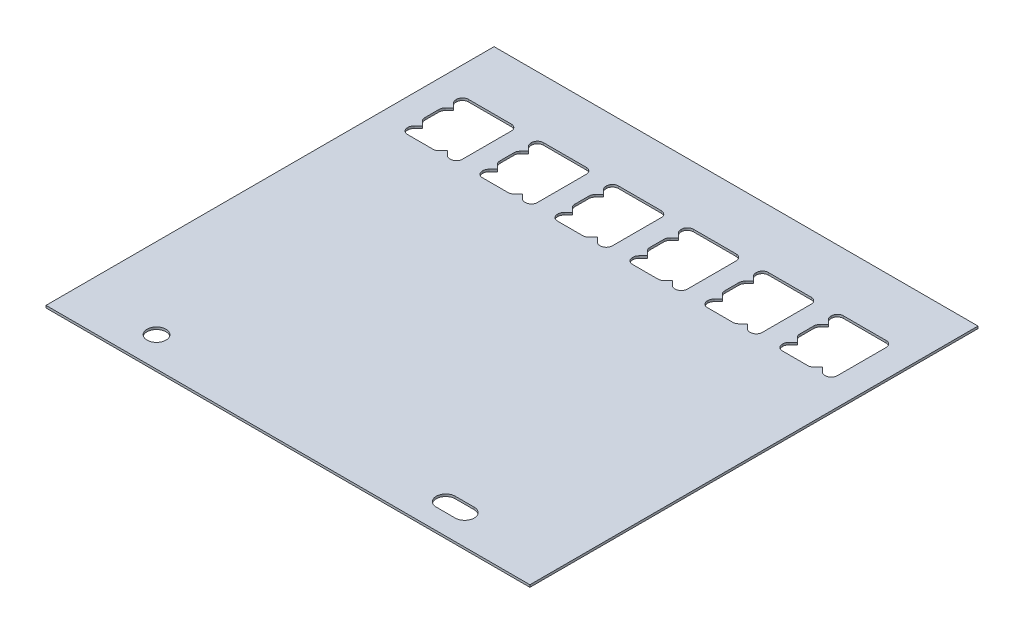
from build123d import *

# Parameters (mm, degrees)
SKETCH1_W           = 81
SKETCH1_H           = 75
BOSS_EXTRUDE1_DEPTH = 0.381
SKETCH2_R           = 1.585
CUT_EXTRUDE1_DEPTH  = 1.381


with BuildPart() as part:
    # Sketch1 → Boss-Extrude1 (new body)
    with BuildSketch(Plane(origin=(0, 0, 0), x_dir=(1, 0, 0), z_dir=(0, 1, 0))):
        with Locations((40.5, 37.5)):
            Rectangle(SKETCH1_W, SKETCH1_H)
    extrude(amount=-BOSS_EXTRUDE1_DEPTH)

    # Sketch2 → Cut-Extrude1 (cut, through all)
    with BuildSketch(Plane(origin=(0, 0, 0), x_dir=(1, 0, 0), z_dir=(0, 1, 0))):
        with Locations(Location((13.5, 5, 0), (0, 0, 270))):  # turned: the seam where the file's is
            Circle(SKETCH2_R)
        with BuildLine():
            Line((61.915, 6.585), (65.085, 6.585))
            ThreePointArc((65.085, 6.585), (66.67, 5), (65.085, 3.415))
            Line((65.085, 3.415), (61.915, 3.415))
            ThreePointArc((61.915, 3.415), (60.33, 5), (61.915, 6.585))
        make_face()
        with BuildLine():
            Line((5.49, 55.02), (9.755786438, 55.02))
            ThreePointArc((9.755786438, 55.02), (10.13846987, 55.096120467), (10.462893219, 55.312893219))
            Line((10.462893219, 55.312893219), (11.17, 56.02))
            Line((11.17, 56.02), (11.877106781, 55.312893219))
            ThreePointArc((11.877106781, 55.312893219), (12.20153013, 55.096120467), (12.584213562, 55.02))
            Line((12.584213562, 55.02), (12.67, 55.02))
            ThreePointArc((12.67, 55.02), (13.377106781, 55.312893219), (13.67, 56.02))
            Line((13.67, 56.02), (13.67, 64.22))
            ThreePointArc((13.67, 64.22), (13.377106781, 64.927106781), (12.67, 65.22))
            Line((12.67, 65.22), (5.49, 65.22))
            ThreePointArc((5.49, 65.22), (4.782893219, 64.927106781), (4.49, 64.22))
            Line((4.49, 64.22), (4.49, 64.134213564))
            ThreePointArc((4.49, 64.134213564), (4.566120467, 63.751530131), (4.782893219, 63.427106782))
            Line((4.782893219, 63.427106782), (5.490000001, 62.72))
            Line((5.490000001, 62.72), (4.782893219, 62.012893218))
            ThreePointArc((4.782893219, 62.012893218), (4.566120467, 61.688469869), (4.49, 61.305786436))
            Line((4.49, 61.305786436), (4.49, 58.934213562))
            ThreePointArc((4.49, 58.934213562), (4.566120467, 58.55153013), (4.782893219, 58.227106781))
            Line((4.782893219, 58.227106781), (5.49, 57.52))
            Line((5.49, 57.52), (4.782893219, 56.812893219))
            ThreePointArc((4.782893219, 56.812893219), (4.566120467, 56.48846987), (4.49, 56.105786438))
            Line((4.49, 56.105786438), (4.49, 56.02))
            ThreePointArc((4.49, 56.02), (4.782893219, 55.312893219), (5.49, 55.02))
        make_face()
        with BuildLine():
            Line((18.04, 55.02), (22.305786438, 55.02))
            ThreePointArc((22.305786438, 55.02), (22.68846987, 55.096120467), (23.012893219, 55.312893219))
            Line((23.012893219, 55.312893219), (23.72, 56.02))
            Line((23.72, 56.02), (24.427106781, 55.312893219))
            ThreePointArc((24.427106781, 55.312893219), (24.75153013, 55.096120467), (25.134213562, 55.02))
            Line((25.134213562, 55.02), (25.22, 55.02))
            ThreePointArc((25.22, 55.02), (25.927106781, 55.312893219), (26.22, 56.02))
            Line((26.22, 56.02), (26.22, 64.22))
            ThreePointArc((26.22, 64.22), (25.927106781, 64.927106781), (25.22, 65.22))
            Line((25.22, 65.22), (18.04, 65.22))
            ThreePointArc((18.04, 65.22), (17.332893219, 64.927106781), (17.04, 64.22))
            Line((17.04, 64.22), (17.04, 64.134213564))
            ThreePointArc((17.04, 64.134213564), (17.116120467, 63.751530131), (17.332893219, 63.427106782))
            Line((17.332893219, 63.427106782), (18.040000001, 62.72))
            Line((18.040000001, 62.72), (17.332893219, 62.012893218))
            ThreePointArc((17.332893219, 62.012893218), (17.116120467, 61.688469869), (17.04, 61.305786436))
            Line((17.04, 61.305786436), (17.04, 58.934213562))
            ThreePointArc((17.04, 58.934213562), (17.116120467, 58.55153013), (17.332893219, 58.227106781))
            Line((17.332893219, 58.227106781), (18.04, 57.52))
            Line((18.04, 57.52), (17.332893219, 56.812893219))
            ThreePointArc((17.332893219, 56.812893219), (17.116120467, 56.48846987), (17.04, 56.105786438))
            Line((17.04, 56.105786438), (17.04, 56.02))
            ThreePointArc((17.04, 56.02), (17.332893219, 55.312893219), (18.04, 55.02))
        make_face()
        with BuildLine():
            Line((30.59, 55.02), (34.855786438, 55.02))
            ThreePointArc((34.855786438, 55.02), (35.23846987, 55.096120467), (35.562893219, 55.312893219))
            Line((35.562893219, 55.312893219), (36.27, 56.02))
            Line((36.27, 56.02), (36.977106781, 55.312893219))
            ThreePointArc((36.977106781, 55.312893219), (37.30153013, 55.096120467), (37.684213562, 55.02))
            Line((37.684213562, 55.02), (37.77, 55.02))
            ThreePointArc((37.77, 55.02), (38.477106781, 55.312893219), (38.77, 56.02))
            Line((38.77, 56.02), (38.77, 64.22))
            ThreePointArc((38.77, 64.22), (38.477106781, 64.927106781), (37.77, 65.22))
            Line((37.77, 65.22), (30.59, 65.22))
            ThreePointArc((30.59, 65.22), (29.882893219, 64.927106781), (29.59, 64.22))
            Line((29.59, 64.22), (29.59, 64.134213564))
            ThreePointArc((29.59, 64.134213564), (29.666120467, 63.751530131), (29.882893219, 63.427106782))
            Line((29.882893219, 63.427106782), (30.590000001, 62.72))
            Line((30.590000001, 62.72), (29.882893219, 62.012893218))
            ThreePointArc((29.882893219, 62.012893218), (29.666120467, 61.688469869), (29.59, 61.305786436))
            Line((29.59, 61.305786436), (29.59, 58.934213562))
            ThreePointArc((29.59, 58.934213562), (29.666120467, 58.55153013), (29.882893219, 58.227106781))
            Line((29.882893219, 58.227106781), (30.59, 57.52))
            Line((30.59, 57.52), (29.882893219, 56.812893219))
            ThreePointArc((29.882893219, 56.812893219), (29.666120467, 56.48846987), (29.59, 56.105786438))
            Line((29.59, 56.105786438), (29.59, 56.02))
            ThreePointArc((29.59, 56.02), (29.882893219, 55.312893219), (30.59, 55.02))
        make_face()
        with BuildLine():
            Line((43.14, 55.02), (47.405786438, 55.02))
            ThreePointArc((47.405786438, 55.02), (47.78846987, 55.096120467), (48.112893219, 55.312893219))
            Line((48.112893219, 55.312893219), (48.82, 56.02))
            Line((48.82, 56.02), (49.527106781, 55.312893219))
            ThreePointArc((49.527106781, 55.312893219), (49.85153013, 55.096120467), (50.234213562, 55.02))
            Line((50.234213562, 55.02), (50.32, 55.02))
            ThreePointArc((50.32, 55.02), (51.027106781, 55.312893219), (51.32, 56.02))
            Line((51.32, 56.02), (51.32, 64.22))
            ThreePointArc((51.32, 64.22), (51.027106781, 64.927106781), (50.32, 65.22))
            Line((50.32, 65.22), (43.14, 65.22))
            ThreePointArc((43.14, 65.22), (42.432893219, 64.927106781), (42.14, 64.22))
            Line((42.14, 64.22), (42.14, 64.134213564))
            ThreePointArc((42.14, 64.134213564), (42.216120467, 63.751530131), (42.432893219, 63.427106782))
            Line((42.432893219, 63.427106782), (43.140000001, 62.72))
            Line((43.140000001, 62.72), (42.432893219, 62.012893218))
            ThreePointArc((42.432893219, 62.012893218), (42.216120467, 61.688469869), (42.14, 61.305786436))
            Line((42.14, 61.305786436), (42.14, 58.934213562))
            ThreePointArc((42.14, 58.934213562), (42.216120467, 58.55153013), (42.432893219, 58.227106781))
            Line((42.432893219, 58.227106781), (43.14, 57.52))
            Line((43.14, 57.52), (42.432893219, 56.812893219))
            ThreePointArc((42.432893219, 56.812893219), (42.216120467, 56.48846987), (42.14, 56.105786438))
            Line((42.14, 56.105786438), (42.14, 56.02))
            ThreePointArc((42.14, 56.02), (42.432893219, 55.312893219), (43.14, 55.02))
        make_face()
        with BuildLine():
            Line((55.69, 55.02), (59.955786438, 55.02))
            ThreePointArc((59.955786438, 55.02), (60.33846987, 55.096120467), (60.662893219, 55.312893219))
            Line((60.662893219, 55.312893219), (61.37, 56.02))
            Line((61.37, 56.02), (62.077106781, 55.312893219))
            ThreePointArc((62.077106781, 55.312893219), (62.40153013, 55.096120467), (62.784213562, 55.02))
            Line((62.784213562, 55.02), (62.87, 55.02))
            ThreePointArc((62.87, 55.02), (63.577106781, 55.312893219), (63.87, 56.02))
            Line((63.87, 56.02), (63.87, 64.22))
            ThreePointArc((63.87, 64.22), (63.577106781, 64.927106781), (62.87, 65.22))
            Line((62.87, 65.22), (55.69, 65.22))
            ThreePointArc((55.69, 65.22), (54.982893219, 64.927106781), (54.69, 64.22))
            Line((54.69, 64.22), (54.69, 64.134213564))
            ThreePointArc((54.69, 64.134213564), (54.766120467, 63.751530131), (54.982893219, 63.427106782))
            Line((54.982893219, 63.427106782), (55.690000001, 62.72))
            Line((55.690000001, 62.72), (54.982893219, 62.012893218))
            ThreePointArc((54.982893219, 62.012893218), (54.766120467, 61.688469869), (54.69, 61.305786436))
            Line((54.69, 61.305786436), (54.69, 58.934213562))
            ThreePointArc((54.69, 58.934213562), (54.766120467, 58.55153013), (54.982893219, 58.227106781))
            Line((54.982893219, 58.227106781), (55.69, 57.52))
            Line((55.69, 57.52), (54.982893219, 56.812893219))
            ThreePointArc((54.982893219, 56.812893219), (54.766120467, 56.48846987), (54.69, 56.105786438))
            Line((54.69, 56.105786438), (54.69, 56.02))
            ThreePointArc((54.69, 56.02), (54.982893219, 55.312893219), (55.69, 55.02))
        make_face()
        with BuildLine():
            Line((68.24, 55.02), (72.505786438, 55.02))
            ThreePointArc((72.505786438, 55.02), (72.88846987, 55.096120467), (73.212893219, 55.312893219))
            Line((73.212893219, 55.312893219), (73.92, 56.02))
            Line((73.92, 56.02), (74.627106781, 55.312893219))
            ThreePointArc((74.627106781, 55.312893219), (74.95153013, 55.096120467), (75.334213562, 55.02))
            Line((75.334213562, 55.02), (75.42, 55.02))
            ThreePointArc((75.42, 55.02), (76.127106781, 55.312893219), (76.42, 56.02))
            Line((76.42, 56.02), (76.42, 64.22))
            ThreePointArc((76.42, 64.22), (76.127106781, 64.927106781), (75.42, 65.22))
            Line((75.42, 65.22), (68.24, 65.22))
            ThreePointArc((68.24, 65.22), (67.532893219, 64.927106781), (67.24, 64.22))
            Line((67.24, 64.22), (67.24, 64.134213564))
            ThreePointArc((67.24, 64.134213564), (67.316120467, 63.751530131), (67.532893219, 63.427106782))
            Line((67.532893219, 63.427106782), (68.240000001, 62.72))
            Line((68.240000001, 62.72), (67.532893219, 62.012893218))
            ThreePointArc((67.532893219, 62.012893218), (67.316120467, 61.688469869), (67.24, 61.305786436))
            Line((67.24, 61.305786436), (67.24, 58.934213562))
            ThreePointArc((67.24, 58.934213562), (67.316120467, 58.55153013), (67.532893219, 58.227106781))
            Line((67.532893219, 58.227106781), (68.24, 57.52))
            Line((68.24, 57.52), (67.532893219, 56.812893219))
            ThreePointArc((67.532893219, 56.812893219), (67.316120467, 56.48846987), (67.24, 56.105786438))
            Line((67.24, 56.105786438), (67.24, 56.02))
            ThreePointArc((67.24, 56.02), (67.532893219, 55.312893219), (68.24, 55.02))
        make_face()
    extrude(amount=-CUT_EXTRUDE1_DEPTH, mode=Mode.SUBTRACT)


solid = part.part
